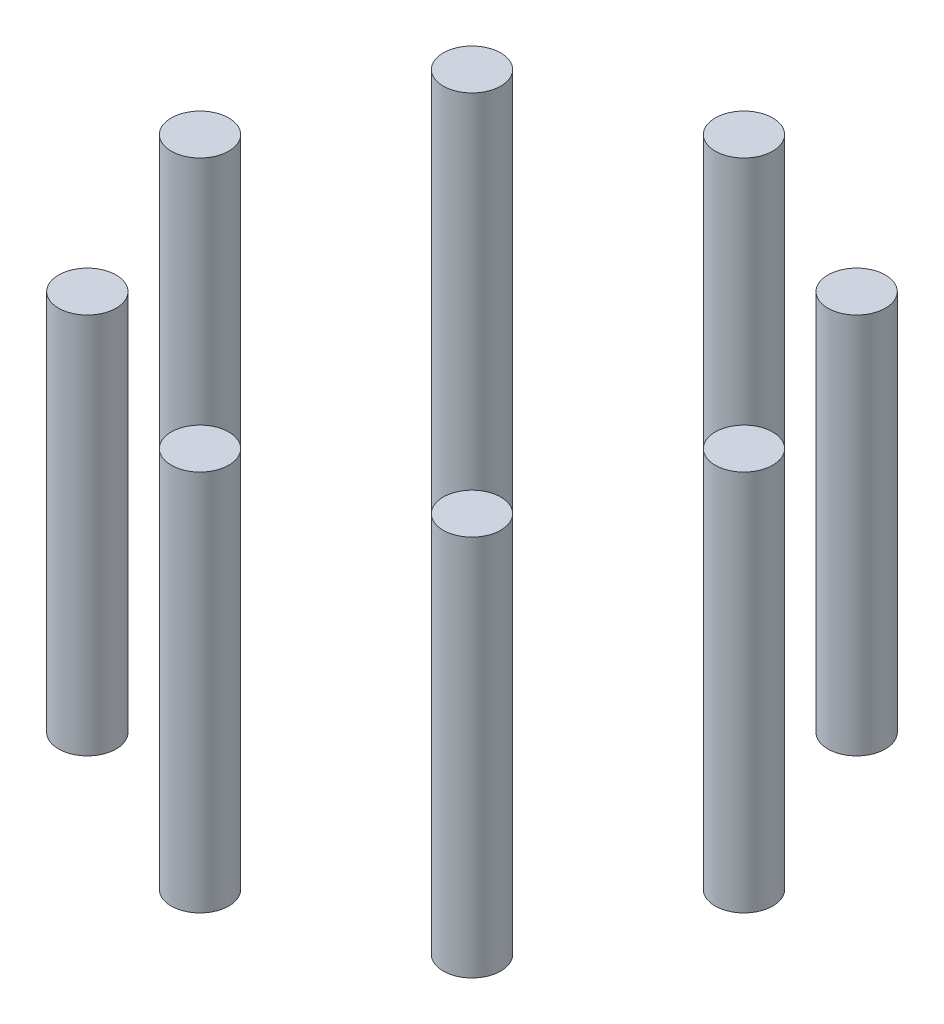
from build123d import *

# Parameters (mm, degrees)
SKETCH1_R             = 5.5
BOSS_EXTRUDE1_DEPTH   = 73
BOSS_EXTRUDE1_2_DEPTH = 73
BOSS_EXTRUDE1_3_DEPTH = 73
BOSS_EXTRUDE1_4_DEPTH = 73
BOSS_EXTRUDE1_5_DEPTH = 73
BOSS_EXTRUDE1_6_DEPTH = 73
BOSS_EXTRUDE1_7_DEPTH = 73
BOSS_EXTRUDE1_8_DEPTH = 73


with BuildPart() as part:
    # Sketch1 → Boss-Extrude1 (new body)
    with BuildSketch(Plane(origin=(0, 0, 0), x_dir=(1, 0, 0), z_dir=(0, 1, 0))):
        with Locations((-52, 0)):
            Circle(SKETCH1_R)
    extrude(amount=BOSS_EXTRUDE1_DEPTH)


with BuildPart() as body_2:
    # Sketch1 → Boss-Extrude1 2 (new body)
    with BuildSketch(Plane(origin=(0, 0, 0), x_dir=(1, 0, 0), z_dir=(0, 1, 0))):
        with Locations((-36.769552622, 36.769552622)):
            Circle(SKETCH1_R)
    extrude(amount=BOSS_EXTRUDE1_2_DEPTH)


with BuildPart() as body_3:
    # Sketch1 → Boss-Extrude1 3 (new body)
    with BuildSketch(Plane(origin=(0, 0, 0), x_dir=(1, 0, 0), z_dir=(0, 1, 0))):
        with Locations((0, 52)):
            Circle(SKETCH1_R)
    extrude(amount=BOSS_EXTRUDE1_3_DEPTH)


with BuildPart() as body_4:
    # Sketch1 → Boss-Extrude1 4 (new body)
    with BuildSketch(Plane(origin=(0, 0, 0), x_dir=(1, 0, 0), z_dir=(0, 1, 0))):
        with Locations((36.769552622, 36.769552622)):
            Circle(SKETCH1_R)
    extrude(amount=BOSS_EXTRUDE1_4_DEPTH)


with BuildPart() as body_5:
    # Sketch1 → Boss-Extrude1 5 (new body)
    with BuildSketch(Plane(origin=(0, 0, 0), x_dir=(1, 0, 0), z_dir=(0, 1, 0))):
        with Locations((52, 0)):
            Circle(SKETCH1_R)
    extrude(amount=BOSS_EXTRUDE1_5_DEPTH)


with BuildPart() as body_6:
    # Sketch1 → Boss-Extrude1 6 (new body)
    with BuildSketch(Plane(origin=(0, 0, 0), x_dir=(1, 0, 0), z_dir=(0, 1, 0))):
        with Locations((36.769552622, -36.769552622)):
            Circle(SKETCH1_R)
    extrude(amount=BOSS_EXTRUDE1_6_DEPTH)


with BuildPart() as body_7:
    # Sketch1 → Boss-Extrude1 7 (new body)
    with BuildSketch(Plane(origin=(0, 0, 0), x_dir=(1, 0, 0), z_dir=(0, 1, 0))):
        with Locations((0, -52)):
            Circle(SKETCH1_R)
    extrude(amount=BOSS_EXTRUDE1_7_DEPTH)


with BuildPart() as body_8:
    # Sketch1 → Boss-Extrude1 8 (new body)
    with BuildSketch(Plane(origin=(0, 0, 0), x_dir=(1, 0, 0), z_dir=(0, 1, 0))):
        with Locations((-36.769552622, -36.769552622)):
            Circle(SKETCH1_R)
    extrude(amount=BOSS_EXTRUDE1_8_DEPTH)


solid = Compound([part.part, body_2.part, body_3.part, body_4.part, body_5.part, body_6.part, body_7.part, body_8.part])
